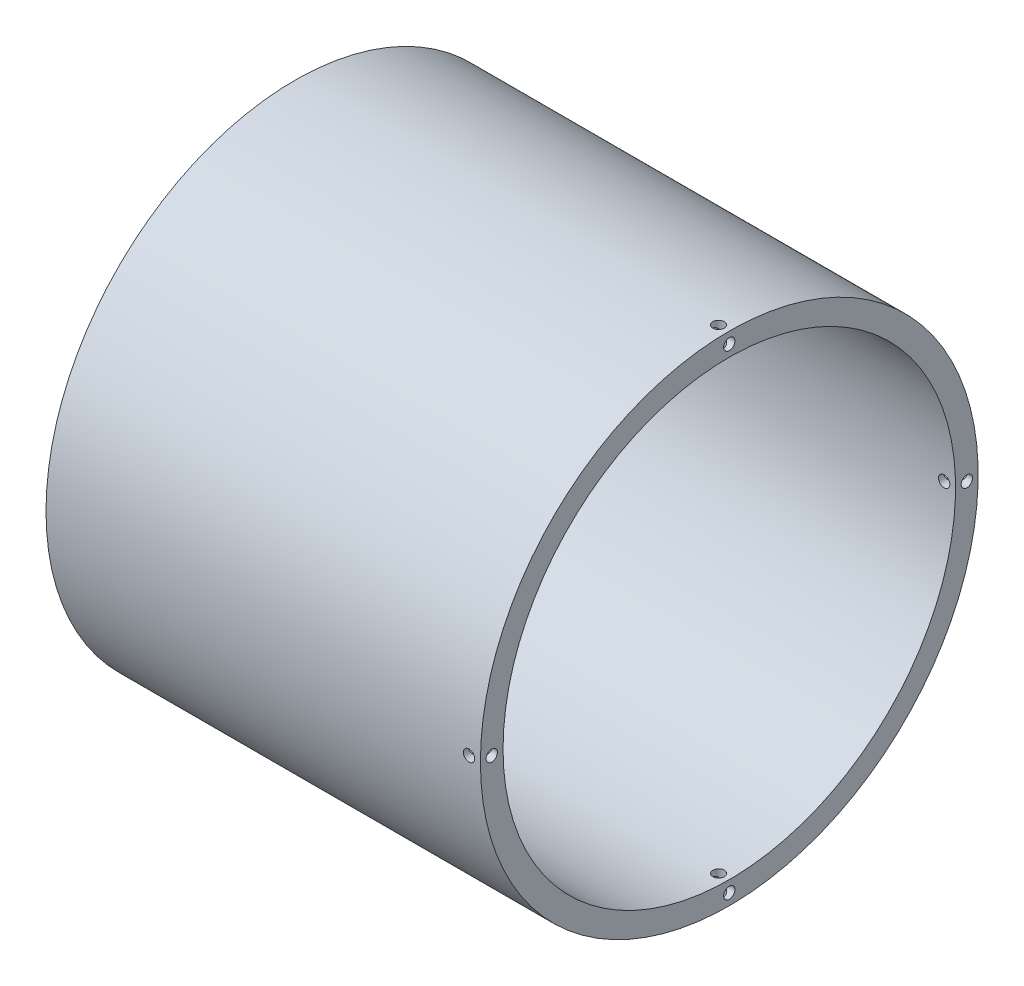
from build123d import *

# Parameters (mm, degrees)
SKETCH1_W               = 96
SKETCH1_H               = 5
SKETCH2_R               = 1.25
CUT_EXTRUDE1_DEPTH      = 56
CUT_EXTRUDE1_DEPTH_BACK = 56
SKETCH4_R               = 1.25
CUT_EXTRUDE2_DEPTH      = 56.0000001
CUT_EXTRUDE2_DEPTH_BACK = 56.0000001
SKETCH5_R               = 1.25
CUT_EXTRUDE3_DEPTH      = 5
CIRPATTERN1_COUNT       = 4


with BuildPart() as part:
    # Sketch1 → Revolve1 (revolve)
    with BuildSketch(Plane.XY):
        with Locations((48, 52.5)):
            Rectangle(SKETCH1_W, SKETCH1_H)
    revolve(axis=Axis((0, 0, 0), (1, 0, 0)))

    # Sketch2 → Cut-Extrude1 (cut, two sides)
    with BuildSketch(Plane(origin=(0, 0, 0), x_dir=(1, 0, 0), z_dir=(0, 1, 0))) as cut_extrude1_sk:
        with Locations((93.637235836, 0)):
            Circle(SKETCH2_R)
    extrude(amount=CUT_EXTRUDE1_DEPTH, mode=Mode.SUBTRACT)
    extrude(cut_extrude1_sk.sketch, amount=-CUT_EXTRUDE1_DEPTH_BACK, mode=Mode.SUBTRACT)

    # Sketch4 → Cut-Extrude2 (cut, two sides)
    with BuildSketch(Plane.XY) as cut_extrude2_sk:
        with Locations((93.481477352, 0)):
            Circle(SKETCH4_R)
    extrude(amount=CUT_EXTRUDE2_DEPTH, mode=Mode.SUBTRACT)
    extrude(cut_extrude2_sk.sketch, amount=-CUT_EXTRUDE2_DEPTH_BACK, mode=Mode.SUBTRACT)

    # Sketch5 → Cut-Extrude3 (cut)
    with BuildSketch(Plane(origin=(96, 0, 0), x_dir=(0, 0, -1), z_dir=(1, 0, 0))):
        with Locations((0, 52.5)):
            Circle(SKETCH5_R)
    cut_extrude3 = extrude(amount=-CUT_EXTRUDE3_DEPTH, mode=Mode.SUBTRACT)

    # CirPattern1: Cut-Extrude3 ×4 about axis
    cirpattern1_axis = Axis((0, 0, 0), (1, 0, 0))
    for i in range(1, CIRPATTERN1_COUNT):
        add(cut_extrude3.rotate(cirpattern1_axis, i * 360 / CIRPATTERN1_COUNT), mode=Mode.SUBTRACT)


solid = part.part
